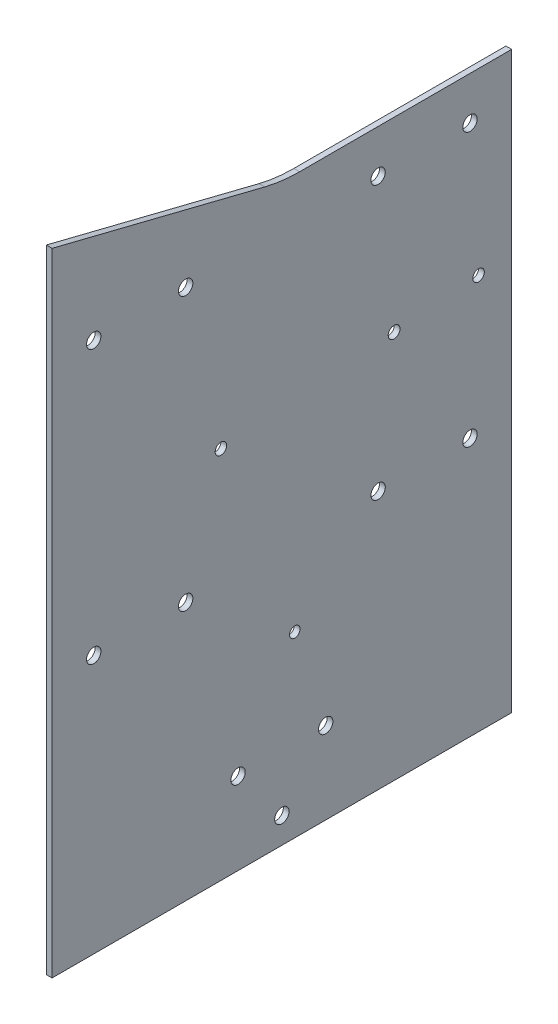
from build123d import *

# Parameters (mm, degrees)
SKETCH_1_R          = 2.5
EXTRUDE_1_DEPTH     = 2
SKETCH_2_R          = 2.000656811
SKETCH_2_R_2        = 2.054404912
SKETCH_2_R_3        = 2
SKETCH_2_R_4        = 1.847510468
CUT_EXTRUDE_1_DEPTH = 3


with BuildPart() as part:
    # 草图1 → 凸台-拉伸1 (new body)
    with BuildSketch(Plane(origin=(0, 0, 0), x_dir=(0, 0, -1), z_dir=(1, 0, 0))):
        with BuildLine():
            Line((80, -100), (-80, -100))
            Line((-80, -100), (-80, 100))
            Line((-80, 100), (-80, 117.438447187))
            Line((-80, 117.438447187), (-80, 120))
            Line((-80, 120), (-77.51492875, 119.378732187))
            Line((-77.51492875, 119.378732187), (-5.971499971, 101.492874993))
            ThreePointArc((-5.971499971, 101.492874993), (0.046118096, 100.374622166), (6.155281281, 100))
            Line((6.155281281, 100), (80, 100))
            Line((80, 100), (80, -100))
        make_face()
        with Locations((-65.5, -10)):
            Circle(SKETCH_1_R, mode=Mode.SUBTRACT)
        with Locations((-33.5, -10)):
            Circle(SKETCH_1_R, mode=Mode.SUBTRACT)
        with Locations((-65.5, 85)):
            Circle(SKETCH_1_R, mode=Mode.SUBTRACT)
        with Locations((-33.5, 85)):
            Circle(SKETCH_1_R, mode=Mode.SUBTRACT)
        with Locations((33.5, 85)):
            Circle(SKETCH_1_R, mode=Mode.SUBTRACT)
        with Locations((65.5, 85)):
            Circle(SKETCH_1_R, mode=Mode.SUBTRACT)
        with Locations((33.5, -10)):
            Circle(SKETCH_1_R, mode=Mode.SUBTRACT)
        with Locations((65.5, -10)):
            Circle(SKETCH_1_R, mode=Mode.SUBTRACT)
        with Locations((0, -91)):
            Circle(SKETCH_1_R, mode=Mode.SUBTRACT)
        with Locations((-15.25, -71.5)):
            Circle(SKETCH_1_R, mode=Mode.SUBTRACT)
        with Locations((15.25, -71.5)):
            Circle(SKETCH_1_R, mode=Mode.SUBTRACT)
    extrude(amount=EXTRUDE_1_DEPTH)

    # 草图2 → 切除-拉伸1 (cut, through all)
    with BuildSketch(Plane(origin=(2, 0, 0), x_dir=(0, 0, -1), z_dir=(1, 0, 0))):
        with Locations((68.472742663, 37.640760233)):
            Circle(SKETCH_2_R)
        with Locations((39.073599545, 35.20346994)):
            Circle(SKETCH_2_R_2)
        with Locations((-21.219558373, 30.20495934)):
            Circle(SKETCH_2_R_3)
        with Locations((4.495464774, -37.903319045)):
            Circle(SKETCH_2_R_4)
    extrude(amount=-CUT_EXTRUDE_1_DEPTH, mode=Mode.SUBTRACT)


solid = part.part
